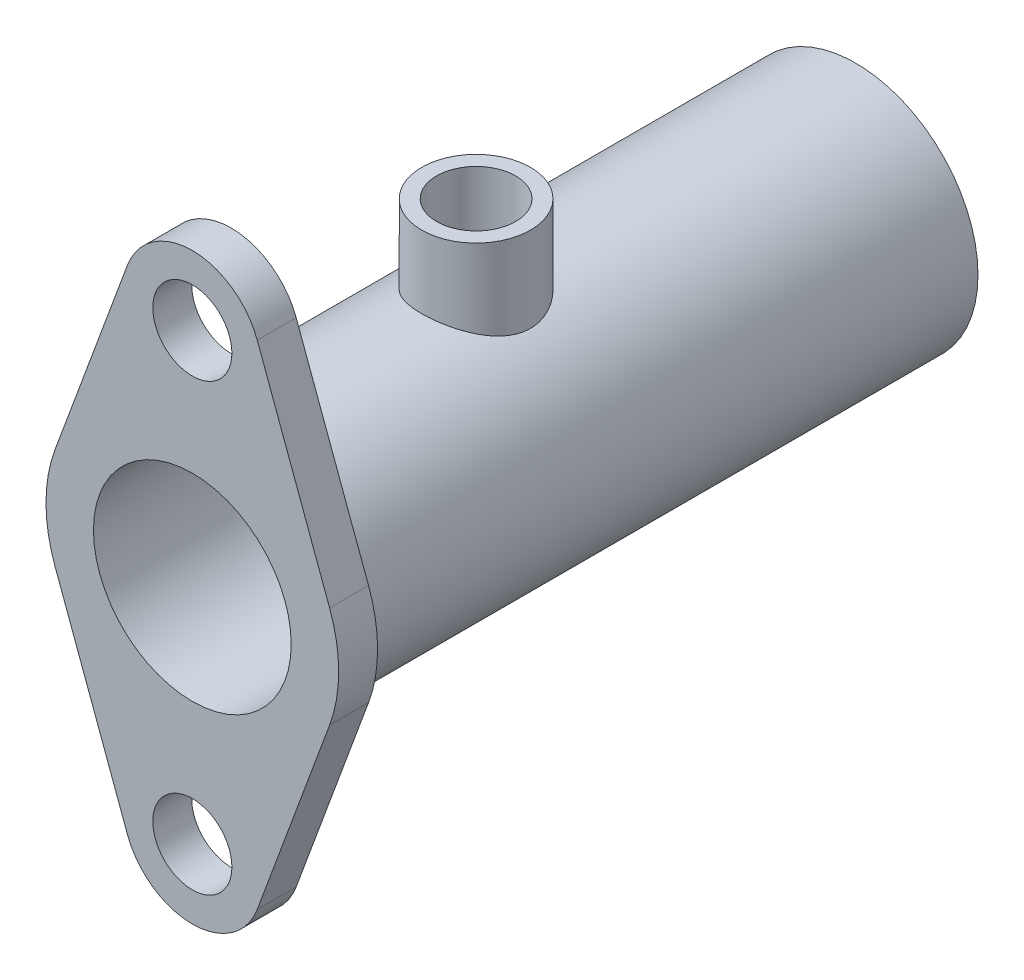
from build123d import *
from build123d.topology import SkipClean

# Parameters (mm, degrees)
SKETCH1_R                = 5.08
SKETCH1_R_2              = 12.7
BOSS_EXTRUDE1_DEPTH      = 5
BOSS_EXTRUDE2_START      = 77.216
SKETCH2_R                = 15.7
SKETCH2_R_2              = 12.7
BOSS_EXTRUDE2_DEPTH      = 77.216
BOSS_EXTRUDE3_START      = 3
SKETCH3_R                = 15.7
BOSS_EXTRUDE3_DEPTH      = 3
BOSS_EXTRUDE5_REACH      = 105.391
BOSS_EXTRUDE5_END_RADIUS = 15.7
SKETCH4_R                = 6.985
CUT_EXTRUDE1_REACH       = 105.391
CUT_EXTRUDE1_END_RADIUS  = 12.7
SKETCH4_5_R              = 5.08


with BuildPart() as part:
    # Sketch1 → Boss-Extrude1 (new body)
    with BuildSketch(Plane.XY):
        with BuildLine():
            Line((17.630429803, 6.515946667), (8.338716799, 31.656866667))
            ThreePointArc((8.338716799, 31.656866667), (0, 37.465), (-8.338716799, 31.656866667))
            Line((-8.338716799, 31.656866667), (-17.630429803, 6.515946667))
            ThreePointArc((-17.630429803, 6.515946667), (-18.796, 0), (-17.630429803, -6.515946667))
            Line((-17.630429803, -6.515946667), (-8.338716799, -31.656866667))
            ThreePointArc((-8.338716799, -31.656866667), (0, -37.465), (8.338716799, -31.656866667))
            Line((8.338716799, -31.656866667), (17.630429803, -6.515946667))
            ThreePointArc((17.630429803, -6.515946667), (18.796, 0), (17.630429803, 6.515946667))
        make_face()
        with Locations((0, 28.575)):
            Circle(SKETCH1_R, mode=Mode.SUBTRACT)
        Circle(SKETCH1_R_2, mode=Mode.SUBTRACT)
        with Locations((0, -28.575)):
            Circle(SKETCH1_R, mode=Mode.SUBTRACT)
    extrude(amount=BOSS_EXTRUDE1_DEPTH)

    # Sketch2 → Boss-Extrude2 (add)
    with SkipClean():  # the faces are left unmerged after this step: merging them gives an invalid solid
        with BuildSketch(Plane(origin=(0, 0, 0), x_dir=(-1, 0, 0), z_dir=(0, 0, -1)).offset(BOSS_EXTRUDE2_START)):
            Circle(SKETCH2_R)
            Circle(SKETCH2_R_2, mode=Mode.SUBTRACT)
        extrude(amount=-BOSS_EXTRUDE2_DEPTH)

    # Sketch3 → Boss-Extrude3 (add)
    with SkipClean():  # the faces are left unmerged after this step: merging them gives an invalid solid
        with BuildSketch(Plane(origin=(0, 0, -77.216), x_dir=(-1, 0, 0), z_dir=(0, 0, -1)).offset(BOSS_EXTRUDE3_START)):
            Circle(SKETCH3_R)
        extrude(amount=-BOSS_EXTRUDE3_DEPTH)

    # Boss-Extrude5: up to this cylinder (the profile starts outside it)
    with SkipClean():  # the faces are left unmerged after this step: merging them gives an invalid solid
        boss_extrude5_end = Plane(origin=(0, 0, -31.448), z_dir=(0, 0, 1)) * Cylinder(BOSS_EXTRUDE5_END_RADIUS, 243.182, mode=Mode.PRIVATE)
        # Sketch4 → Boss-Extrude5 (add, up to the surface)
        with BuildSketch(Plane(origin=(0, 25, 0), x_dir=(1, 0, 0), z_dir=(0, 1, 0)), mode=Mode.PRIVATE) as boss_extrude5_sk1:
            with Locations((0, 31.448)):
                Circle(SKETCH4_R)
        boss_extrude5_tool1 = extrude(boss_extrude5_sk1.sketch, amount=-BOSS_EXTRUDE5_REACH, mode=Mode.PRIVATE) - boss_extrude5_end
        add(boss_extrude5_tool1.solids().sort_by_distance((0, 25, -31.448))[0])

    # Cut-Extrude1: up to this cylinder (the profile starts outside it)
    with SkipClean():  # the faces are left unmerged after this step: merging them gives an invalid solid
        cut_extrude1_end = Plane(origin=(0, 0, -31.448), z_dir=(0, 0, -1)) * Cylinder(CUT_EXTRUDE1_END_RADIUS, 237.182, mode=Mode.PRIVATE)
        # Sketch4_5 → Cut-Extrude1 (cut, up to the surface)
        with BuildSketch(Plane(origin=(0, 25, 0), x_dir=(1, 0, 0), z_dir=(0, 1, 0)), mode=Mode.PRIVATE) as cut_extrude1_sk1:
            with Locations((0, 31.448)):
                Circle(SKETCH4_5_R)
        cut_extrude1_tool1 = extrude(cut_extrude1_sk1.sketch, amount=-CUT_EXTRUDE1_REACH, mode=Mode.PRIVATE) - cut_extrude1_end
        add(cut_extrude1_tool1.solids().sort_by_distance((0, 25, -31.448))[0], mode=Mode.SUBTRACT)


solid = part.part
